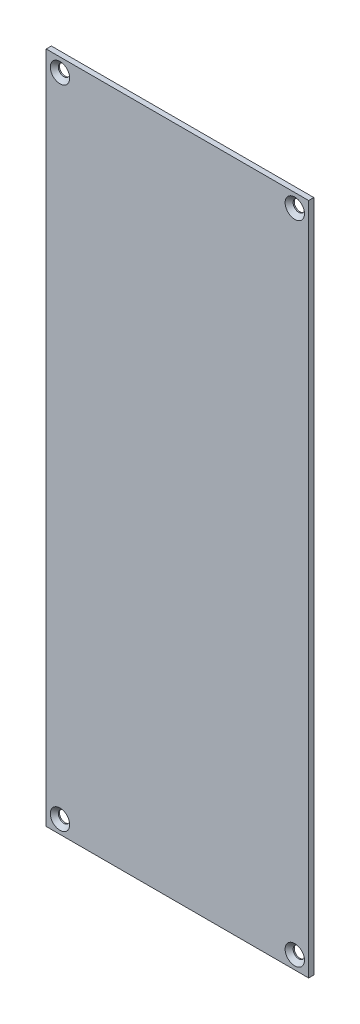
from build123d import *

# Parameters (mm, degrees)
SKETCH1_W                                      = 50.8
SKETCH1_H                                      = 130.33
BOSS_EXTRUDE1_DEPTH                            = 1
CSK_FOR_M2_FLAT_HEAD_MACHINE_SCREW1_AT_2_COUNT = 2
CSK_FOR_M2_FLAT_HEAD_MACHINE_SCREW1_AT_2_PITCH = 133.137981433
CSK_FOR_M2_FLAT_HEAD_MACHINE_SCREW1_AT_3_COUNT = 2
CSK_FOR_M2_FLAT_HEAD_MACHINE_SCREW1_AT_3_PITCH = 125.14
CSK_FOR_M2_FLAT_HEAD_MACHINE_SCREW1_AT_4_COUNT = 2
CSK_FOR_M2_FLAT_HEAD_MACHINE_SCREW1_AT_4_PITCH = 45.45


with BuildPart() as part:
    # Sketch1 → Boss-Extrude1 (new body)
    with BuildSketch(Plane.XY):
        with Locations((25.4, 65.165)):
            Rectangle(SKETCH1_W, SKETCH1_H)
    extrude(amount=BOSS_EXTRUDE1_DEPTH)

    # Sketch4 → CSK for M2 Flat Head Machine Screw1 (revolve, cut)
    with BuildSketch(Plane(origin=(48.1225, 127.7025, 1), x_dir=(0, -1, 0), z_dir=(1, 0, 0))):
        Polygon((0, 0), (0, 1), (1.1, 1), (1.1, 0.775), (1.875, 0), align=None)
    csk_for_m2_flat_head_machine_screw1 = revolve(axis=Axis((48.1225, 127.7025, 7.35), (0, 0, -1)), mode=Mode.SUBTRACT)

    # CSK for M2 Flat Head Machine Screw1 at 2: CSK for M2 Flat Head Machine Screw1 ×2
    with Locations(*[Vector(-0.341375162, -0.939927124, 0) * (i * CSK_FOR_M2_FLAT_HEAD_MACHINE_SCREW1_AT_2_PITCH) for i in range(1, CSK_FOR_M2_FLAT_HEAD_MACHINE_SCREW1_AT_2_COUNT)]):
        add(csk_for_m2_flat_head_machine_screw1, mode=Mode.SUBTRACT)

    # CSK for M2 Flat Head Machine Screw1 at 3: CSK for M2 Flat Head Machine Screw1 ×2
    with Locations(*[(0, -i * CSK_FOR_M2_FLAT_HEAD_MACHINE_SCREW1_AT_3_PITCH, 0) for i in range(1, CSK_FOR_M2_FLAT_HEAD_MACHINE_SCREW1_AT_3_COUNT)]):
        add(csk_for_m2_flat_head_machine_screw1, mode=Mode.SUBTRACT)

    # CSK for M2 Flat Head Machine Screw1 at 4: CSK for M2 Flat Head Machine Screw1 ×2
    with Locations(*[(-i * CSK_FOR_M2_FLAT_HEAD_MACHINE_SCREW1_AT_4_PITCH, 0, 0) for i in range(1, CSK_FOR_M2_FLAT_HEAD_MACHINE_SCREW1_AT_4_COUNT)]):
        add(csk_for_m2_flat_head_machine_screw1, mode=Mode.SUBTRACT)


solid = part.part
